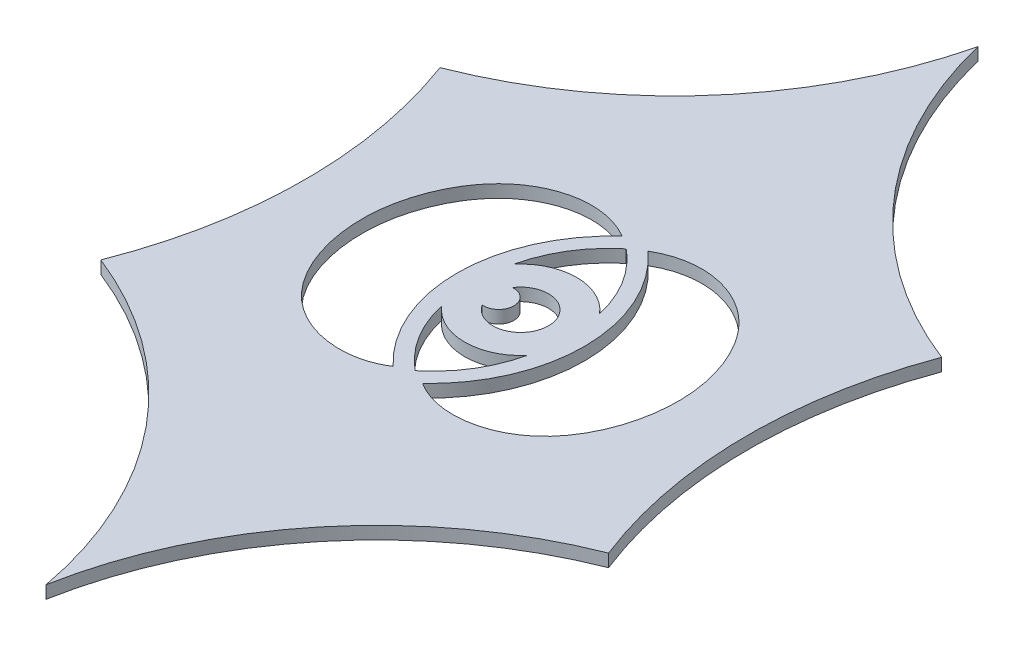
from build123d import *

# Parameters (mm, degrees)
EXTRUDE_1_DEPTH     = 2
CUT_EXTRUDE_2_DEPTH = 3


with BuildPart() as part:
    # Эскиз2 → Бобышка-Вытянуть1 (new body)
    with BuildSketch(Plane(origin=(0, 0, 0), x_dir=(1, 0, 0), z_dir=(0, 1, 0))):
        with BuildLine():
            ThreePointArc((-34.560822595, -73.294650793), (-29.912438938, -99.847233064), (-35.042219755, -126.311028042))
            ThreePointArc((-35.042219755, -126.311028042), (-8.723554926, -145.4763519), (4.999999999, -175))
            ThreePointArc((4.999999999, -175), (18.723554924, -145.4763519), (45.042219753, -126.311028042))
            ThreePointArc((45.042219753, -126.311028042), (39.912438936, -99.847233064), (44.560822593, -73.294650793))
            ThreePointArc((44.560822593, -73.294650793), (19.227048475, -55.497690672), (4.999999999, -28))
            ThreePointArc((4.999999999, -28), (-9.227048477, -55.497690672), (-34.560822595, -73.294650793))
        make_face()
    extrude(amount=EXTRUDE_1_DEPTH)

    # Эскиз5 → Вырез-Вытянуть2 (cut, through all)
    with BuildSketch(Plane(origin=(0, 2, 0), x_dir=(1, 0, 0), z_dir=(0, 1, 0))):
        with BuildLine():
            ThreePointArc((1.1922114, -102.391848867), (9.263771174, -100.007354542), (1.1922114, -97.622860217))
            ThreePointArc((1.1922114, -97.622860217), (3.802790428, -100.007354542), (1.1922114, -102.391848867))
        make_face()
        with BuildLine():
            ThreePointArc((-1.894766012, -94.327614743), (4.875778497, -91.169950109), (11.646323005, -94.327614743))
            add(Edge.make_bspline(
                [(11.646323005, -94.327614743), (10.113303771, -87.718633088), (4.875778497, -83.368495621)],
                knots=[0, 0, 0, 1, 1, 1], degree=2))
            add(Edge.make_bspline(
                [(-1.894766012, -94.327614743), (-0.361746778, -87.718633088), (4.875778497, -83.368495621)],
                knots=[0, 0, 0, 1, 1, 1], degree=2))
        make_face()
        with BuildLine():
            add(Edge.make_bspline(
                [(11.646323005, -105.687094341), (10.113303771, -112.296075996), (4.875778497, -116.646213463)],
                knots=[0, 0, 0, 1, 1, 1], degree=2))
            ThreePointArc((11.646323005, -105.687094341), (4.875778497, -108.844758976), (-1.894766012, -105.687094341))
            add(Edge.make_bspline(
                [(-1.894766012, -105.687094341), (-0.361746778, -112.296075996), (4.875778497, -116.646213463)],
                knots=[0, 0, 0, 1, 1, 1], degree=2))
        make_face()
        with BuildLine():
            ThreePointArc((6.916781621, -81.95103194), (14.912317424, -99.810070996), (7.206797889, -117.796144427))
            add(Edge.make_bspline(
                [(6.916781621, -81.95103194), (12.307611516, -78.787526654), (22.389316178, -80.793310488), (29.731357531, -92.811077081), (30.434704422, -105.116682284), (25.64381117, -115.001664232), (17.091486552, -120.227210357), (10.646188457, -120.056173748), (7.206797889, -117.796144427)],
                knots=[0, 0, 0, 0, 0.238043411, 0.386081267, 0.575651621, 0.751375083, 0.825495316, 1, 1, 1, 1], degree=3))
        make_face()
        with BuildLine():
            ThreePointArc((2.544759104, -117.796144427), (-5.160760431, -99.810070996), (2.834775372, -81.95103194))
            add(Edge.make_bspline(
                [(2.834775372, -81.95103194), (-2.556054523, -78.787526654), (-12.637759184, -80.793310488), (-19.979800538, -92.811077081), (-20.683147428, -105.116682284), (-15.892254177, -115.001664232), (-7.339929559, -120.227210357), (-0.894631464, -120.056173748), (2.544759104, -117.796144427)],
                knots=[0, 0, 0, 0, 0.238043411, 0.386081267, 0.575651621, 0.751375083, 0.825495316, 1, 1, 1, 1], degree=3))
        make_face()
    extrude(amount=-CUT_EXTRUDE_2_DEPTH, mode=Mode.SUBTRACT)


solid = part.part
